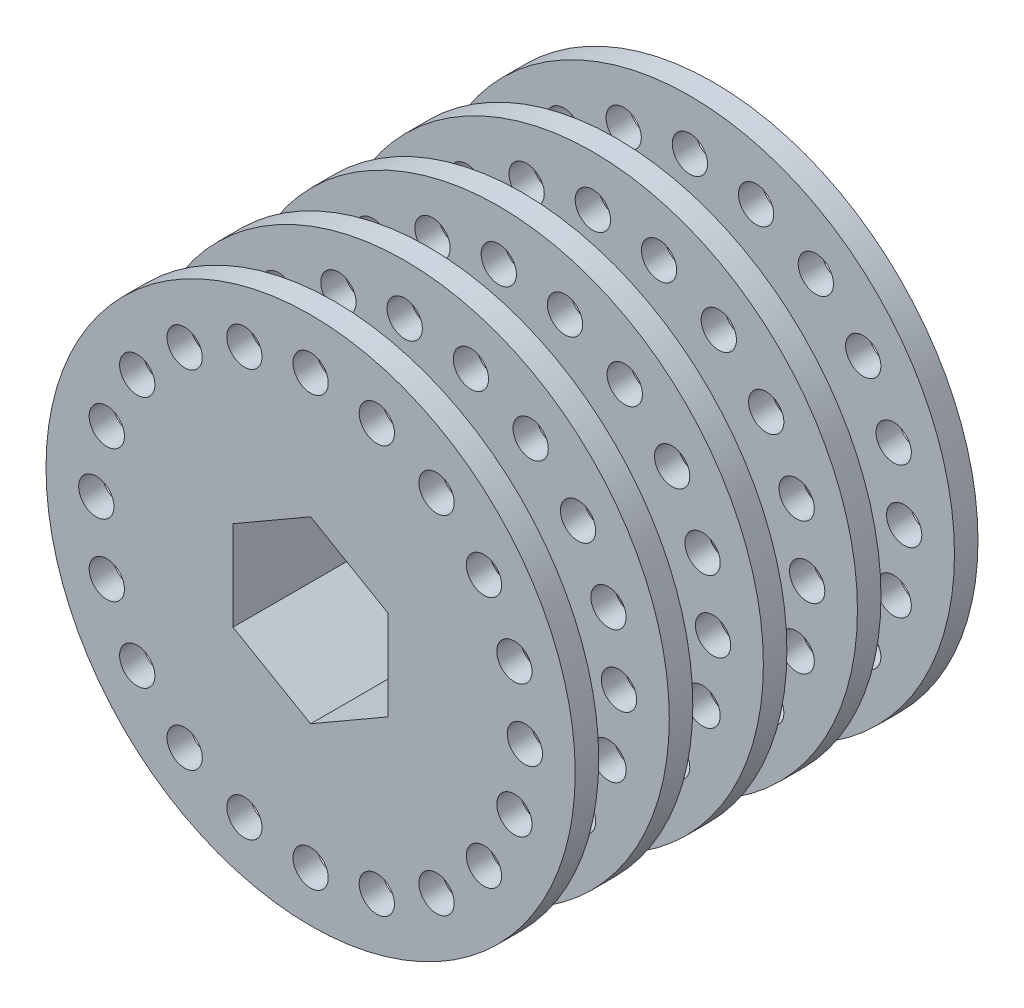
from build123d import *

# Parameters (mm, degrees)
SKETCH1_R           = 10.16
SKETCH1_R_2         = 22.5
SKETCH1_R_3         = 1.5
BOSS_EXTRUDE1_DEPTH = 2
SKETCH1_3_R         = 10.16
BOSS_EXTRUDE2_DEPTH = 6.25
LPATTERN2_COUNT     = 4
LPATTERN2_PITCH     = 8
SKETCH2_R           = 22.5
SKETCH2_R_2         = 1.5
SKETCH2_R_3         = 10.16
BOSS_EXTRUDE3_DEPTH = 2
CUT_EXTRUDE1_DEPTH  = 35.25
SKETCH4_R           = 10.16
BOSS_EXTRUDE5_DEPTH = 34.25
CHAMFER1_SIZE       = 1


with BuildPart() as part:
    # Sketch1 → Boss-Extrude1 (new body)
    with BuildSketch(Plane.XY):
        Circle(SKETCH1_R)
        Circle(SKETCH1_R_2)
        with Locations((-5.630860181, 17.330005678)):
            Circle(SKETCH1_R_3, mode=Mode.SUBTRACT)
        with Locations((-10.710532534, 14.741783339)):
            Circle(SKETCH1_R_3, mode=Mode.SUBTRACT)
        with Locations((-14.741783339, 10.710532534)):
            Circle(SKETCH1_R_3, mode=Mode.SUBTRACT)
        with Locations((-17.330005678, 5.630860181)):
            Circle(SKETCH1_R_3, mode=Mode.SUBTRACT)
        with Locations((-18.221846316, 0)):
            Circle(SKETCH1_R_3, mode=Mode.SUBTRACT)
        with Locations((-17.330005678, -5.630860181)):
            Circle(SKETCH1_R_3, mode=Mode.SUBTRACT)
        with Locations((-14.741783339, -10.710532534)):
            Circle(SKETCH1_R_3, mode=Mode.SUBTRACT)
        with Locations((-10.710532534, -14.741783339)):
            Circle(SKETCH1_R_3, mode=Mode.SUBTRACT)
        with Locations((-5.630860181, -17.330005678)):
            Circle(SKETCH1_R_3, mode=Mode.SUBTRACT)
        with Locations((0, -18.221846316)):
            Circle(SKETCH1_R_3, mode=Mode.SUBTRACT)
        with Locations((5.630860181, -17.330005678)):
            Circle(SKETCH1_R_3, mode=Mode.SUBTRACT)
        with Locations((10.710532534, -14.741783339)):
            Circle(SKETCH1_R_3, mode=Mode.SUBTRACT)
        with Locations((14.741783339, -10.710532534)):
            Circle(SKETCH1_R_3, mode=Mode.SUBTRACT)
        with Locations((17.330005678, -5.630860181)):
            Circle(SKETCH1_R_3, mode=Mode.SUBTRACT)
        with Locations((18.221846316, 0)):
            Circle(SKETCH1_R_3, mode=Mode.SUBTRACT)
        with Locations((17.330005678, 5.630860181)):
            Circle(SKETCH1_R_3, mode=Mode.SUBTRACT)
        with Locations((14.741783339, 10.710532534)):
            Circle(SKETCH1_R_3, mode=Mode.SUBTRACT)
        with Locations((10.710532534, 14.741783339)):
            Circle(SKETCH1_R_3, mode=Mode.SUBTRACT)
        with Locations((5.630860181, 17.330005678)):
            Circle(SKETCH1_R_3, mode=Mode.SUBTRACT)
        with Locations((0, 18.221846316)):
            Circle(SKETCH1_R_3, mode=Mode.SUBTRACT)
        Circle(SKETCH1_R, mode=Mode.SUBTRACT)
    extrude(amount=BOSS_EXTRUDE1_DEPTH)

    # Sketch1_3 → Boss-Extrude2 (add)
    with BuildSketch(Plane.XY):
        Circle(SKETCH1_3_R)
    extrude(amount=-BOSS_EXTRUDE2_DEPTH)


with BuildPart() as lpattern2_1:
    # LPattern2: pattern copy
    add(part.part.moved(Location(Vector(0, 0, -1) * (1 * LPATTERN2_PITCH))))


with BuildPart() as lpattern2_2:
    # LPattern2: pattern copy
    add(part.part.moved(Location(Vector(0, 0, -1) * (2 * LPATTERN2_PITCH))))


with BuildPart() as lpattern2_3:
    # LPattern2: pattern copy
    add(part.part.moved(Location(Vector(0, 0, -1) * (3 * LPATTERN2_PITCH))))

    # Sketch2 → Boss-Extrude3 (add)
    with BuildSketch(Plane(origin=(0, 0, -30.25), x_dir=(-1, 0, 0), z_dir=(0, 0, -1))):
        Circle(SKETCH2_R)
        with Locations((5.630860181, 17.330005678)):
            Circle(SKETCH2_R_2, mode=Mode.SUBTRACT)
        with Locations((0, 18.221846316)):
            Circle(SKETCH2_R_2, mode=Mode.SUBTRACT)
        with Locations((-5.630860181, 17.330005678)):
            Circle(SKETCH2_R_2, mode=Mode.SUBTRACT)
        with Locations((-10.710532534, 14.741783339)):
            Circle(SKETCH2_R_2, mode=Mode.SUBTRACT)
        with Locations((-14.741783339, 10.710532534)):
            Circle(SKETCH2_R_2, mode=Mode.SUBTRACT)
        with Locations((-17.330005678, 5.630860181)):
            Circle(SKETCH2_R_2, mode=Mode.SUBTRACT)
        with Locations((-18.221846316, 0)):
            Circle(SKETCH2_R_2, mode=Mode.SUBTRACT)
        with Locations((-17.330005678, -5.630860181)):
            Circle(SKETCH2_R_2, mode=Mode.SUBTRACT)
        with Locations((-14.741783339, -10.710532534)):
            Circle(SKETCH2_R_2, mode=Mode.SUBTRACT)
        with Locations((-10.710532534, -14.741783339)):
            Circle(SKETCH2_R_2, mode=Mode.SUBTRACT)
        with Locations((-5.630860181, -17.330005678)):
            Circle(SKETCH2_R_2, mode=Mode.SUBTRACT)
        with Locations((0, -18.221846316)):
            Circle(SKETCH2_R_2, mode=Mode.SUBTRACT)
        with Locations((5.630860181, -17.330005678)):
            Circle(SKETCH2_R_2, mode=Mode.SUBTRACT)
        with Locations((10.710532534, -14.741783339)):
            Circle(SKETCH2_R_2, mode=Mode.SUBTRACT)
        with Locations((14.741783339, -10.710532534)):
            Circle(SKETCH2_R_2, mode=Mode.SUBTRACT)
        with Locations((17.330005678, -5.630860181)):
            Circle(SKETCH2_R_2, mode=Mode.SUBTRACT)
        with Locations((18.221846316, 0)):
            Circle(SKETCH2_R_2, mode=Mode.SUBTRACT)
        with Locations((17.330005678, 5.630860181)):
            Circle(SKETCH2_R_2, mode=Mode.SUBTRACT)
        with Locations((14.741783339, 10.710532534)):
            Circle(SKETCH2_R_2, mode=Mode.SUBTRACT)
        with Locations((10.710532534, 14.741783339)):
            Circle(SKETCH2_R_2, mode=Mode.SUBTRACT)
        Circle(SKETCH2_R_3, mode=Mode.SUBTRACT)
        Circle(SKETCH2_R_3)
    extrude(amount=BOSS_EXTRUDE3_DEPTH)


with BuildPart() as cut_extrude1_tool:
    # Sketch3 → Cut-Extrude1 (new body, through all)
    with BuildSketch(Plane(origin=(0, 0, -32.25), x_dir=(-1, 0, 0), z_dir=(0, 0, -1))):
        Polygon((6.6, -3.810511777), (6.6, 3.810511777), (0, 7.621023553), (-6.6, 3.810511777), (-6.6, -3.810511777), (0, -7.621023553), align=None)
    extrude(amount=-CUT_EXTRUDE1_DEPTH)


with BuildPart() as part_1:
    add(part.part)

    # Cut-Extrude1: cut by cut_extrude1_tool
    add(cut_extrude1_tool.part, mode=Mode.SUBTRACT)



with BuildPart() as lpattern2_1_1:
    add(lpattern2_1.part)

    # Cut-Extrude1: cut by cut_extrude1_tool
    add(cut_extrude1_tool.part, mode=Mode.SUBTRACT)


with BuildPart() as lpattern2_2_1:
    add(lpattern2_2.part)

    # Cut-Extrude1: cut by cut_extrude1_tool
    add(cut_extrude1_tool.part, mode=Mode.SUBTRACT)


with BuildPart() as lpattern2_3_1:
    add(lpattern2_3.part)

    # Cut-Extrude1: cut by cut_extrude1_tool
    add(cut_extrude1_tool.part, mode=Mode.SUBTRACT)


with BuildPart() as part_2:
    add(part_1.part)

    add(lpattern2_1_1.part)  # Boss-Extrude5 merges LPattern2_1

    add(lpattern2_2_1.part)  # Boss-Extrude5 merges LPattern2_2

    add(lpattern2_3_1.part)  # Boss-Extrude5 merges LPattern2_3
    # Sketch4 → Boss-Extrude5 (add)
    with BuildSketch(Plane(origin=(0, 0, -32.25), x_dir=(-1, 0, 0), z_dir=(0, 0, -1))):
        Circle(SKETCH4_R)
        Polygon((0, 7.621023553), (6.6, 3.810511777), (6.6, -3.810511777), (0, -7.621023553), (-6.6, -3.810511777), (-6.6, 3.810511777), align=None, mode=Mode.SUBTRACT)
    extrude(amount=-BOSS_EXTRUDE5_DEPTH)

    # Chamfer1
    chamfer1_edges = [part_2.edges().sort_by_distance(p)[0] for p in [
        (-10.16, 0, -6),
        (-10.16, 0, -8),
        (-10.16, 0, -14),
        (-10.16, 0, -16),
        (-10.16, 0, -22),
        (-10.16, 0, -24),
        (-10.16, 0, -30.25),
        (-10.16, 0, 0),
    ]]
    chamfer(chamfer1_edges, length=CHAMFER1_SIZE)


solid = part_2.part
